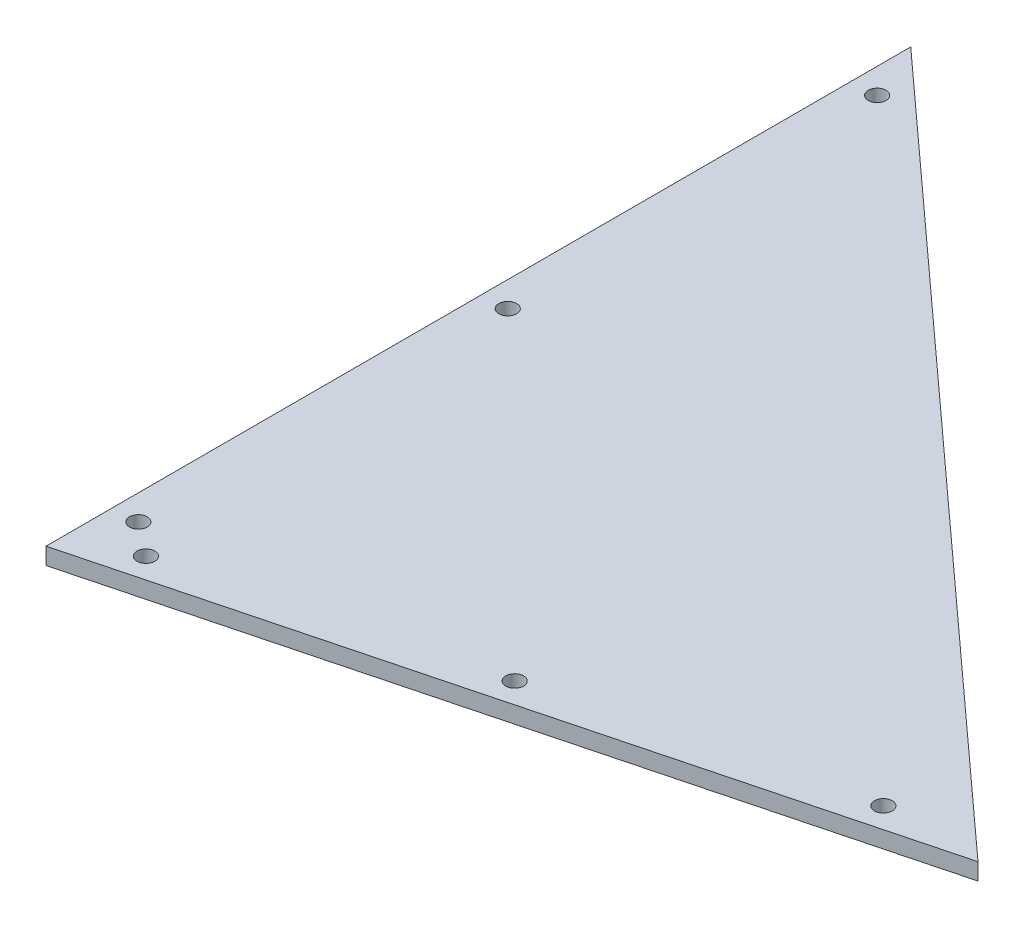
from build123d import *

# Parameters (mm, degrees)
BOSS_EXTRUDE1_DEPTH = 6.35
SKETCH2_R           = 3.3655
CUT_EXTRUDE1_DEPTH  = 7.35


with BuildPart() as part:
    # Sketch1 → Boss-Extrude1 (new body)
    with BuildSketch(Plane(origin=(0, 0, 0), x_dir=(1, 0, 0), z_dir=(0, 1, 0))):
        Polygon((0, 0), (0, 327.025), (279.580480146, 72.886286408), align=None)
    extrude(amount=BOSS_EXTRUDE1_DEPTH)

    # Sketch2 → Cut-Extrude1 (cut, through all)
    with BuildSketch(Plane(origin=(0, 6.35, 0), x_dir=(1, 0, 0), z_dir=(0, 1, 0))):
        with Locations((9.525, 25.4)):
            Circle(SKETCH2_R)
        with Locations((9.525, 165.1)):
            Circle(SKETCH2_R)
        with Locations((9.525, 304.8)):
            Circle(SKETCH2_R)
        with Locations((22.175659142, 15.624524524)):
            Circle(SKETCH2_R)
        with Locations((132.778926013, 44.458659806)):
            Circle(SKETCH2_R)
        with Locations((243.382192884, 73.292795089)):
            Circle(SKETCH2_R)
    extrude(amount=-CUT_EXTRUDE1_DEPTH, mode=Mode.SUBTRACT)


solid = part.part
